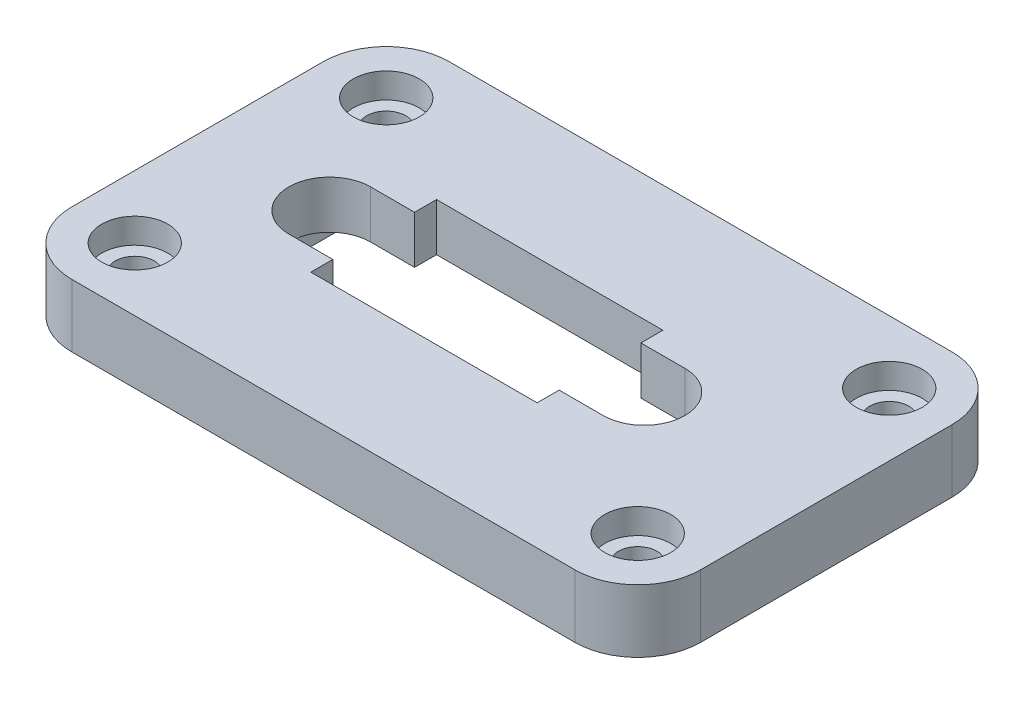
from build123d import *

# Parameters (mm, degrees)
SKETCH1_W           = 50
SKETCH1_H           = 30
SKETCH1_R           = 1.55
BOSS_EXTRUDE1_DEPTH = 5
SKETCH2_R           = 2.625
CUT_EXTRUDE1_DEPTH  = 2
SKETCH3_W           = 31.5
SKETCH3_H           = 13
CUT_EXTRUDE2_DEPTH  = 1.2
FILLET1_R           = 5


with BuildPart() as part:
    # Sketch1 → Boss-Extrude1 (new body)
    with BuildSketch(Plane(origin=(0, 0, 0), x_dir=(1, 0, 0), z_dir=(0, 1, 0))):
        Rectangle(SKETCH1_W, SKETCH1_H)
        with Locations((-20, -10)):
            Circle(SKETCH1_R, mode=Mode.SUBTRACT)
        with Locations((20, -10)):
            Circle(SKETCH1_R, mode=Mode.SUBTRACT)
        with BuildLine():
            Line((7, -5), (-11, -5))
            Line((-11, -5), (-11, -3.25))
            Line((-11, -3.25), (-14.5, -3.25))
            ThreePointArc((-14.5, -3.25), (-17.75, 0), (-14.5, 3.25))
            Line((-14.5, 3.25), (-11, 3.25))
            Line((-11, 3.25), (-11, 5))
            Line((-11, 5), (7, 5))
            Line((7, 5), (7, 3.25))
            Line((7, 3.25), (10.5, 3.25))
            ThreePointArc((10.5, 3.25), (12.798097039, 2.298097039), (13.75, 0))
            ThreePointArc((13.75, 0), (12.798097039, -2.298097039), (10.5, -3.25))
            Line((10.5, -3.25), (7, -3.25))
            Line((7, -3.25), (7, -5))
        make_face(mode=Mode.SUBTRACT)
        with Locations((-20, 10)):
            Circle(SKETCH1_R, mode=Mode.SUBTRACT)
        with Locations((20, 10)):
            Circle(SKETCH1_R, mode=Mode.SUBTRACT)
    extrude(amount=BOSS_EXTRUDE1_DEPTH)

    # Sketch2 → Cut-Extrude1 (cut)
    with BuildSketch(Plane(origin=(0, 5, 0), x_dir=(1, 0, 0), z_dir=(0, 1, 0))):
        with Locations((-20, 10)):
            Circle(SKETCH2_R)
        with Locations((20, 10)):
            Circle(SKETCH2_R)
        with Locations((20, -10)):
            Circle(SKETCH2_R)
        with Locations((-20, -10)):
            Circle(SKETCH2_R)
    extrude(amount=-CUT_EXTRUDE1_DEPTH, mode=Mode.SUBTRACT)

    # Sketch3 → Cut-Extrude2 (cut)
    with BuildSketch(Plane.XZ):
        with Locations((-2, 0)):
            Rectangle(SKETCH3_W, SKETCH3_H)
    extrude(amount=-CUT_EXTRUDE2_DEPTH, mode=Mode.SUBTRACT)

    # Fillet1
    fillet1_edges = [part.edges().sort_by_distance(p)[0] for p in [
        (-25, 2.5, 15),
        (-25, 2.5, -15),
        (25, 2.5, -15),
        (25, 2.5, 15),
    ]]
    fillet(fillet1_edges, radius=FILLET1_R)


solid = part.part
